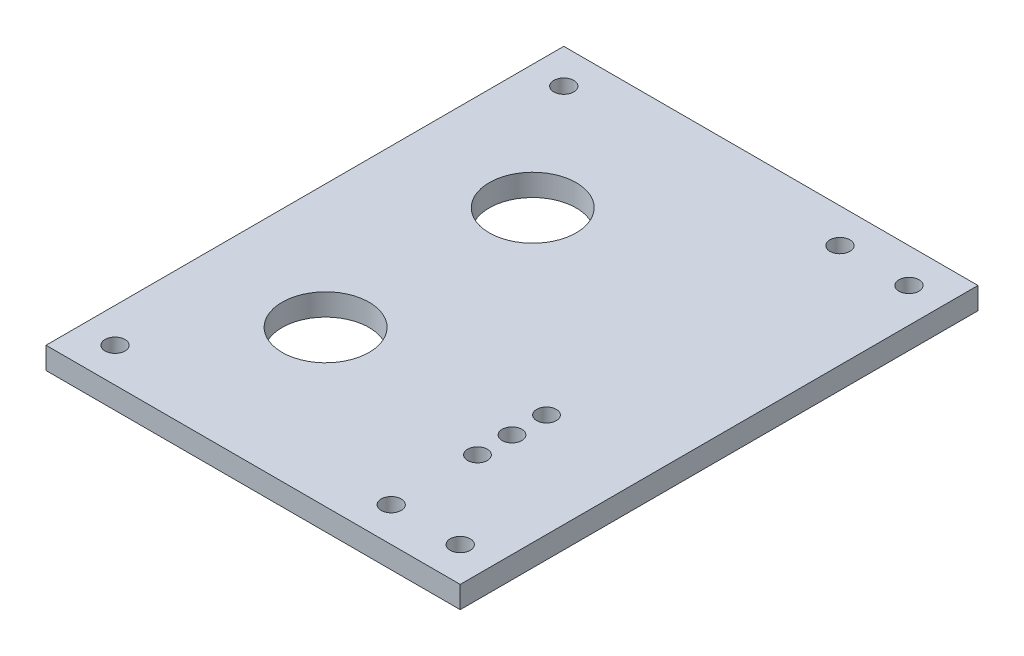
from build123d import *

# Parameters (mm, degrees)
SKETCH1_W           = 60
SKETCH1_H           = 75
BOSS_EXTRUDE1_DEPTH = 3.175
SKETCH2_R           = 1.45
CUT_EXTRUDE1_DEPTH  = 4.175
SKETCH3_R           = 6.3
SKETCH3_R_2         = 1.425
CUT_EXTRUDE2_DEPTH  = 4.175


with BuildPart() as part:
    # Sketch1 → Boss-Extrude1 (new body)
    with BuildSketch(Plane(origin=(0, 0, 0), x_dir=(1, 0, 0), z_dir=(0, 1, 0))):
        Rectangle(SKETCH1_W, SKETCH1_H)
    extrude(amount=BOSS_EXTRUDE1_DEPTH)

    # Sketch2 → Cut-Extrude1 (cut, through all)
    with BuildSketch(Plane(origin=(0, 3.175, 0), x_dir=(1, 0, 0), z_dir=(0, 1, 0))):
        with Locations((25, 32.5)):
            Circle(SKETCH2_R)
        with Locations((-25, 32.5)):
            Circle(SKETCH2_R)
        with Locations((15, 32.5)):
            Circle(SKETCH2_R)
        with Locations((25, -32.5)):
            Circle(SKETCH2_R)
        with Locations((15, -32.5)):
            Circle(SKETCH2_R)
        with Locations((-25, -32.5)):
            Circle(SKETCH2_R)
    extrude(amount=-CUT_EXTRUDE1_DEPTH, mode=Mode.SUBTRACT)

    # Sketch3 → Cut-Extrude2 (cut, through all)
    with BuildSketch(Plane(origin=(0, 3.175, 0), x_dir=(-1, 0, 0), z_dir=(0, 1, 0))):
        with Locations((12, -15)):
            Circle(SKETCH3_R)
        with Locations((12, 15)):
            Circle(SKETCH3_R)
        with Locations((-15, 20)):
            Circle(SKETCH3_R_2)
        with Locations((-15, 15)):
            Circle(SKETCH3_R_2)
        with Locations((-15, 10)):
            Circle(SKETCH3_R_2)
    extrude(amount=-CUT_EXTRUDE2_DEPTH, mode=Mode.SUBTRACT)


solid = part.part
